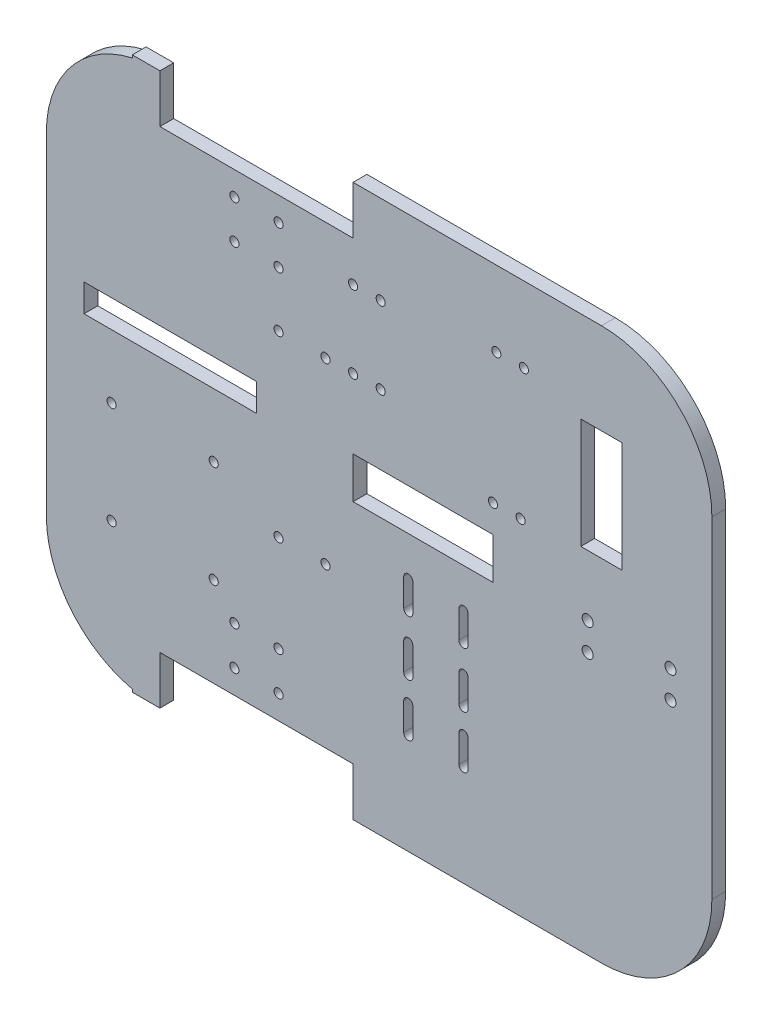
from build123d import *

# Parameters (mm, degrees)
BOSS_EXTRUDE1_DEPTH     = 10
CUT_EXTRUDE1_DEPTH      = 10
CUT_EXTRUDE2_DEPTH      = 315.006369362
CUT_EXTRUDE2_DEPTH_BACK = 315.006369362
SKETCH6_W               = 5
SKETCH6_H               = 17.5
SKETCH6_R               = 1.65
SKETCH6_R_2             = 1.5
MOTOR_DEPTH             = 169.07736314
SKETCH7_R               = 1.5
SKETCH7_R_2             = 1.65
SKETCH7_W               = 62.5
SKETCH7_H               = 10
ADN1_BANHBI_L298_DEPTH  = 10
CUT_EXTRUDE8_DEPTH      = 10
CUT_EXTRUDE9_DEPTH      = 10
SKETCH15_R              = 2
BANH_TRUOC_DEPTH        = 10
SKETCH17_W              = 15
SKETCH17_H              = 40
ADN_DEPTH               = 10
BATTERRY_ANGTEN_R       = 1.65
BATTERRY_ANGTEN_W       = 50.7
BATTERRY_ANGTEN_H       = 15
BATTERY_ANGTEN_DEPTH    = 10
SKETCH18_R              = 1.475
SKETCH18_R_2            = 1.5
BOSS_EXTRUDE2_DEPTH     = 5


with BuildPart() as part:
    # Sketch1 → Boss-Extrude1 (new body)
    with BuildSketch(Plane.XY):
        with BuildLine():
            Line((-60, 100), (-95, 100))
            ThreePointArc((-95, 100), (-123.284271247, 88.284271247), (-135, 60))
            Line((-135, 60), (-135, -60))
            ThreePointArc((-135, -60), (-123.284271247, -88.284271247), (-95, -100))
            Line((-95, -100), (-60, -100))
            Line((-60, -100), (-60, -82.5))
            Line((-60, -82.5), (0, -82.5))
            Line((0, -82.5), (0, -100))
            Line((0, -100), (95, -100))
            ThreePointArc((95, -100), (123.284271247, -88.284271247), (135, -60))
            Line((135, -60), (135, 60))
            ThreePointArc((135, 60), (123.284271247, 88.284271247), (95, 100))
            Line((95, 100), (0, 100))
            Line((0, 100), (0, 82.5))
            Line((0, 82.5), (-60, 82.5))
            Line((-60, 82.5), (-60, 100))
        make_face()
    extrude(amount=BOSS_EXTRUDE1_DEPTH)

    # Sketch2 → Cut-Extrude1 (cut)
    with BuildSketch(Plane(origin=(0, 0, 0), x_dir=(-1, 0, 0), z_dir=(0, 0, -1))):
        with BuildLine():
            ThreePointArc((-61.475, 87.5), (-60, 86.025), (-58.525, 87.5))
            Line((-58.525, 87.5), (-61.475, 87.5))
        make_face()
        with BuildLine():
            Line((-61.475, 87.5), (-58.525, 87.5))
            ThreePointArc((-58.525, 87.5), (-60, 88.975), (-61.475, 87.5))
        make_face()
        with BuildLine():
            ThreePointArc((-61.475, 87.5), (-60, 86.025), (-58.525, 87.5))
            Line((-58.525, 87.5), (-61.475, 87.5))
        make_face()
        with BuildLine():
            Line((-61.475, 87.5), (-58.525, 87.5))
            ThreePointArc((-58.525, 87.5), (-60, 88.975), (-61.475, 87.5))
        make_face()
        with BuildLine():
            ThreePointArc((-26.475, 87.5), (-25, 86.025), (-23.525, 87.5))
            Line((-23.525, 87.5), (-26.475, 87.5))
        make_face()
        with BuildLine():
            Line((-26.475, 87.5), (-23.525, 87.5))
            ThreePointArc((-23.525, 87.5), (-25, 88.975), (-26.475, 87.5))
        make_face()
        with BuildLine():
            ThreePointArc((-26.475, 87.5), (-25, 86.025), (-23.525, 87.5))
            Line((-23.525, 87.5), (-26.475, 87.5))
        make_face()
        with BuildLine():
            Line((-26.475, 87.5), (-23.525, 87.5))
            ThreePointArc((-23.525, 87.5), (-25, 88.975), (-26.475, 87.5))
        make_face()
        with BuildLine():
            ThreePointArc((76.025, 87.5), (77.5, 86.025), (78.975, 87.5))
            Line((78.975, 87.5), (76.025, 87.5))
        make_face()
        with BuildLine():
            Line((76.025, 87.5), (78.975, 87.5))
            ThreePointArc((78.975, 87.5), (77.5, 88.975), (76.025, 87.5))
        make_face()
        with BuildLine():
            ThreePointArc((76.025, 87.5), (77.5, 86.025), (78.975, 87.5))
            Line((78.975, 87.5), (76.025, 87.5))
        make_face()
        with BuildLine():
            Line((76.025, 87.5), (78.975, 87.5))
            ThreePointArc((78.975, 87.5), (77.5, 88.975), (76.025, 87.5))
        make_face()
        with BuildLine():
            ThreePointArc((78.975, -87.5), (77.5, -86.025), (76.025, -87.5))
            Line((76.025, -87.5), (78.975, -87.5))
        make_face()
        with BuildLine():
            Line((78.975, -87.5), (76.025, -87.5))
            ThreePointArc((76.025, -87.5), (77.5, -88.975), (78.975, -87.5))
        make_face()
        with BuildLine():
            ThreePointArc((78.975, -87.5), (77.5, -86.025), (76.025, -87.5))
            Line((76.025, -87.5), (78.975, -87.5))
        make_face()
        with BuildLine():
            Line((78.975, -87.5), (76.025, -87.5))
            ThreePointArc((76.025, -87.5), (77.5, -88.975), (78.975, -87.5))
        make_face()
        with BuildLine():
            ThreePointArc((-58.525, -87.5), (-60, -86.025), (-61.475, -87.5))
            Line((-61.475, -87.5), (-58.525, -87.5))
        make_face()
        with BuildLine():
            Line((-58.525, -87.5), (-61.475, -87.5))
            ThreePointArc((-61.475, -87.5), (-60, -88.975), (-58.525, -87.5))
        make_face()
        with BuildLine():
            ThreePointArc((-58.525, -87.5), (-60, -86.025), (-61.475, -87.5))
            Line((-61.475, -87.5), (-58.525, -87.5))
        make_face()
        with BuildLine():
            Line((-58.525, -87.5), (-61.475, -87.5))
            ThreePointArc((-61.475, -87.5), (-60, -88.975), (-58.525, -87.5))
        make_face()
        with BuildLine():
            ThreePointArc((-23.525, -87.5), (-25, -86.025), (-26.475, -87.5))
            Line((-26.475, -87.5), (-23.525, -87.5))
        make_face()
        with BuildLine():
            Line((-23.525, -87.5), (-26.475, -87.5))
            ThreePointArc((-26.475, -87.5), (-25, -88.975), (-23.525, -87.5))
        make_face()
        with BuildLine():
            ThreePointArc((-23.525, -87.5), (-25, -86.025), (-26.475, -87.5))
            Line((-26.475, -87.5), (-23.525, -87.5))
        make_face()
        with BuildLine():
            Line((-23.525, -87.5), (-26.475, -87.5))
            ThreePointArc((-26.475, -87.5), (-25, -88.975), (-23.525, -87.5))
        make_face()
    extrude(amount=-CUT_EXTRUDE1_DEPTH, mode=Mode.SUBTRACT)

    # 3DSketch1 → Cut-Extrude2 (cut, two sides)
    with BuildSketch(Plane(origin=(135, 60, 0), x_dir=(-0.9998285763251313, 0, 0.018515344006020944), z_dir=(0, 1, 0))) as cut_extrude2_sk:
        Polygon((0, 0), (269.953715608, -4.999142882), (270.046292328, 0), (0.09257672, 4.999142882), align=None)
    extrude(amount=CUT_EXTRUDE2_DEPTH, mode=Mode.SUBTRACT)
    extrude(cut_extrude2_sk.sketch, amount=-CUT_EXTRUDE2_DEPTH_BACK, mode=Mode.SUBTRACT)

    # Sketch6 → motor (cut, through all)
    with BuildSketch(Plane(origin=(0, 0, 5), x_dir=(-1, 0, 0), z_dir=(0, 0, -1))):
        with Locations((-2.5, -91.25)):
            Rectangle(SKETCH6_W, SKETCH6_H)
        with Locations((22, -59.87)):
            Circle(SKETCH6_R)
        with Locations((22, -73.87)):
            Circle(SKETCH6_R)
        with Locations((38, -59.87)):
            Circle(SKETCH6_R)
        with Locations((38, -73.87)):
            Circle(SKETCH6_R)
        with Locations((62.5, -91.25)):
            Rectangle(SKETCH6_W, SKETCH6_H)
        with Locations((-95, -28.5)):
            Circle(SKETCH6_R_2)
        with Locations((-95, 28.5)):
            Circle(SKETCH6_R_2)
        with Locations((22, 73.87)):
            Circle(SKETCH6_R)
        with Locations((22, 59.87)):
            Circle(SKETCH6_R)
        with Locations((-2.5, 91.25)):
            Rectangle(SKETCH6_W, SKETCH6_H)
        with Locations((62.5, 91.25)):
            Rectangle(SKETCH6_W, SKETCH6_H)
        with Locations((38, 59.87)):
            Circle(SKETCH6_R)
        with Locations((38, 73.87)):
            Circle(SKETCH6_R)
    extrude(amount=-MOTOR_DEPTH, mode=Mode.SUBTRACT)

    # Sketch7 → adn1_banhbi_l298 (cut)
    with BuildSketch(Plane.XY.offset(10)):
        with Locations((95, 40)):
            Circle(SKETCH7_R)
        with Locations((95, -40)):
            Circle(SKETCH7_R)
        with Locations((5, 40)):
            Circle(SKETCH7_R_2)
        with Locations((-61.25, 15)):
            Rectangle(SKETCH7_W, SKETCH7_H)
        with Locations((5, 67.9)):
            Circle(SKETCH7_R_2)
        with Locations((55.7, 24.789271045)):
            Circle(SKETCH7_R_2)
        with Locations((-82.5, -50)):
            Circle(SKETCH7_R_2)
        with Locations((-45.5, -50)):
            Circle(SKETCH7_R_2)
        with Locations((56.9, 72.650671163)):
            Circle(SKETCH7_R_2)
        with Locations((-82.5, -13)):
            Circle(SKETCH7_R_2)
        with Locations((-45.5, -13)):
            Circle(SKETCH7_R_2)
    extrude(amount=-ADN1_BANHBI_L298_DEPTH, mode=Mode.SUBTRACT)

    # Sketch10 → Cut-Extrude8 (cut)
    with BuildSketch(Plane.XY.offset(10)):
        with BuildLine():
            Line((-106.152761212, -60), (-106.152761212, 60))
            ThreePointArc((-106.152761212, 60), (-97.408877026, 84.96107418), (-75, 99.009311271))
            Line((-75, 99.009311271), (-75, 100))
            Line((-75, 100), (-95, 100))
            ThreePointArc((-95, 100), (-123.284271247, 88.284271247), (-135, 60))
            Line((-135, 60), (-135, -60))
            ThreePointArc((-135, -60), (-123.284271247, -88.284271247), (-95, -100))
            Line((-95, -100), (-75, -100))
            Line((-75, -100), (-75, -99.009311271))
            ThreePointArc((-75, -99.009311271), (-97.408877026, -84.96107418), (-106.152761212, -60))
        make_face()
    extrude(amount=-CUT_EXTRUDE8_DEPTH, mode=Mode.SUBTRACT)

    # Sketch14 → Cut-Extrude9 (cut)
    with BuildSketch(Plane.XY.offset(10)):
        with BuildLine():
            ThreePointArc((68.55, 72.650671163), (66.824719548, 74.298952951), (65.256869268, 72.500267044))
            Line((65.256869268, 72.500267044), (66.9, 72.650671163))
            Line((66.9, 72.650671163), (66.858643543, 71.001189534))
            ThreePointArc((66.858643543, 71.001189534), (68.052011685, 71.469413749), (68.55, 72.650671163))
        make_face()
        with BuildLine():
            Line((66.9, 72.650671163), (65.256869268, 72.500267044))
            ThreePointArc((65.256869268, 72.500267044), (65.772532654, 71.445964816), (66.858643543, 71.001189534))
            Line((66.858643543, 71.001189534), (66.9, 72.650671163))
        make_face()
        with BuildLine():
            ThreePointArc((68.55, 72.650671163), (66.824719548, 74.298952951), (65.256869268, 72.500267044))
            Line((65.256869268, 72.500267044), (66.9, 72.650671163))
            Line((66.9, 72.650671163), (66.858643543, 71.001189534))
            ThreePointArc((66.858643543, 71.001189534), (68.052011685, 71.469413749), (68.55, 72.650671163))
        make_face()
        with BuildLine():
            Line((66.9, 72.650671163), (65.256869268, 72.500267044))
            ThreePointArc((65.256869268, 72.500267044), (65.772532654, 71.445964816), (66.858643543, 71.001189534))
            Line((66.858643543, 71.001189534), (66.9, 72.650671163))
        make_face()
        with BuildLine():
            ThreePointArc((67.35, 24.789271045), (66.881257414, 25.94128273), (65.741356457, 26.438752673))
            Line((65.741356457, 26.438752673), (65.7, 24.789271045))
            Line((65.7, 24.789271045), (64.119592884, 25.263415902))
            ThreePointArc((64.119592884, 25.263415902), (65.460387544, 23.156761972), (67.35, 24.789271045))
        make_face()
        with BuildLine():
            Line((65.7, 24.789271045), (65.741356457, 26.438752673))
            ThreePointArc((65.741356457, 26.438752673), (64.731742098, 26.125301222), (64.119592884, 25.263415902))
            Line((64.119592884, 25.263415902), (65.7, 24.789271045))
        make_face()
        with BuildLine():
            ThreePointArc((67.35, 24.789271045), (66.881257414, 25.94128273), (65.741356457, 26.438752673))
            Line((65.741356457, 26.438752673), (65.7, 24.789271045))
            Line((65.7, 24.789271045), (64.119592884, 25.263415902))
            ThreePointArc((64.119592884, 25.263415902), (65.460387544, 23.156761972), (67.35, 24.789271045))
        make_face()
        with BuildLine():
            Line((65.7, 24.789271045), (65.741356457, 26.438752673))
            ThreePointArc((65.741356457, 26.438752673), (64.731742098, 26.125301222), (64.119592884, 25.263415902))
            Line((64.119592884, 25.263415902), (65.7, 24.789271045))
        make_face()
        with BuildLine():
            Line((16.580407116, 39.525855142), (15, 40))
            Line((15, 40), (13.35, 40))
            ThreePointArc((13.35, 40), (14.760387544, 38.367490928), (16.580407116, 39.525855142))
        make_face()
        with BuildLine():
            ThreePointArc((16.65, 40), (16.166726189, 41.166726189), (15, 41.65))
            Line((15, 41.65), (15, 40))
            Line((15, 40), (16.580407116, 39.525855142))
            ThreePointArc((16.580407116, 39.525855142), (16.632509072, 39.760387544), (16.65, 40))
        make_face()
        with BuildLine():
            Line((15, 40), (15, 41.65))
            ThreePointArc((15, 41.65), (13.833273811, 41.166726189), (13.35, 40))
            Line((13.35, 40), (15, 40))
        make_face()
        with BuildLine():
            Line((15, 67.9), (13.35, 67.9))
            ThreePointArc((13.35, 67.9), (13.833273811, 66.733273811), (15, 66.25))
            Line((15, 66.25), (15, 67.9))
        make_face()
        with BuildLine():
            Line((16.643130732, 68.050404119), (15, 67.9))
            Line((15, 67.9), (15, 66.25))
            ThreePointArc((15, 66.25), (16.166726189, 66.733273811), (16.65, 67.9))
            ThreePointArc((16.65, 67.9), (16.648281788, 67.975280452), (16.643130732, 68.050404119))
        make_face()
        with BuildLine():
            ThreePointArc((16.643130732, 68.050404119), (14.924719548, 69.548281788), (13.35, 67.9))
            Line((13.35, 67.9), (15, 67.9))
            Line((15, 67.9), (16.643130732, 68.050404119))
        make_face()
    extrude(amount=-CUT_EXTRUDE9_DEPTH, mode=Mode.SUBTRACT)

    # Sketch15 → banh_truoc (cut)
    with BuildSketch(Plane.XY.offset(10)):
        with Locations((120, 5)):
            Circle(SKETCH15_R)
        with Locations((90, 5)):
            Circle(SKETCH15_R)
        with Locations((90, -5)):
            Circle(SKETCH15_R)
        with Locations((120, -5)):
            Circle(SKETCH15_R)
    extrude(amount=-BANH_TRUOC_DEPTH, mode=Mode.SUBTRACT)

    # Sketch17 → adn (cut)
    with BuildSketch(Plane.XY.offset(10)):
        with Locations((95, 47)):
            Rectangle(SKETCH17_W, SKETCH17_H)
    extrude(amount=-ADN_DEPTH, mode=Mode.SUBTRACT)

    # batterry_angten → battery_angten (cut)
    with BuildSketch(Plane.XY.offset(10)):
        with Locations((-5, 39.87)):
            Circle(BATTERRY_ANGTEN_R)
        with Locations((-22, 39.87)):
            Circle(BATTERRY_ANGTEN_R)
        with Locations((-5, -24.87)):
            Circle(BATTERRY_ANGTEN_R)
        with Locations((-22, -24.87)):
            Circle(BATTERRY_ANGTEN_R)
        with Locations((30.35, 7.289271045)):
            Rectangle(BATTERRY_ANGTEN_W, BATTERRY_ANGTEN_H)
        with BuildLine():
            ThreePointArc((43.35, -24.5), (45, -26.15), (46.65, -24.5))
            Line((46.65, -24.5), (46.65, -14.5))
            ThreePointArc((46.65, -14.5), (45, -12.85), (43.35, -14.5))
            Line((43.35, -14.5), (43.35, -24.5))
        make_face()
        with BuildLine():
            Line((43.35, -34.5), (43.35, -44.5))
            ThreePointArc((43.35, -44.5), (45, -46.15), (46.65, -44.5))
            Line((46.65, -44.5), (46.65, -34.5))
            ThreePointArc((46.65, -34.5), (45, -32.85), (43.35, -34.5))
        make_face()
        with BuildLine():
            Line((43.35, -53.5), (43.35, -63.5))
            ThreePointArc((43.35, -63.5), (45, -65.15), (46.65, -63.5))
            Line((46.65, -63.5), (46.65, -53.5))
            ThreePointArc((46.65, -53.5), (45, -51.85), (43.35, -53.5))
        make_face()
        with BuildLine():
            ThreePointArc((23.35, -24.5), (25, -26.15), (26.65, -24.5))
            Line((26.65, -24.5), (26.65, -14.5))
            ThreePointArc((26.65, -14.5), (25, -12.85), (23.35, -14.5))
            Line((23.35, -14.5), (23.35, -24.5))
        make_face()
        with BuildLine():
            Line((23.35, -34.5), (23.35, -44.5))
            ThreePointArc((23.35, -44.5), (25, -46.15), (26.65, -44.5))
            Line((26.65, -44.5), (26.65, -34.5))
            ThreePointArc((26.65, -34.5), (25, -32.85), (23.35, -34.5))
        make_face()
        with BuildLine():
            Line((23.35, -53.5), (23.35, -63.5))
            ThreePointArc((23.35, -63.5), (25, -65.15), (26.65, -63.5))
            Line((26.65, -63.5), (26.65, -53.5))
            ThreePointArc((26.65, -53.5), (25, -51.85), (23.35, -53.5))
        make_face()
    extrude(amount=-BATTERY_ANGTEN_DEPTH, mode=Mode.SUBTRACT)

    # Sketch18 → Boss-Extrude2 (add)
    with BuildSketch(Plane.XY.offset(10)):
        with Locations((-77.5, -87.5)):
            Circle(SKETCH18_R)
        with Locations((-77.5, 87.5)):
            Circle(SKETCH18_R)
        with Locations((95, -28.5)):
            Circle(SKETCH18_R_2)
        with Locations((95, -40)):
            Circle(SKETCH18_R_2)
        with Locations((60, -87.5)):
            Circle(SKETCH18_R)
        with Locations((25, -87.5)):
            Circle(SKETCH18_R)
        with Locations((60, 87.5)):
            Circle(SKETCH18_R)
        with Locations((25, 87.5)):
            Circle(SKETCH18_R)
    extrude(amount=-BOSS_EXTRUDE2_DEPTH)


solid = part.part
